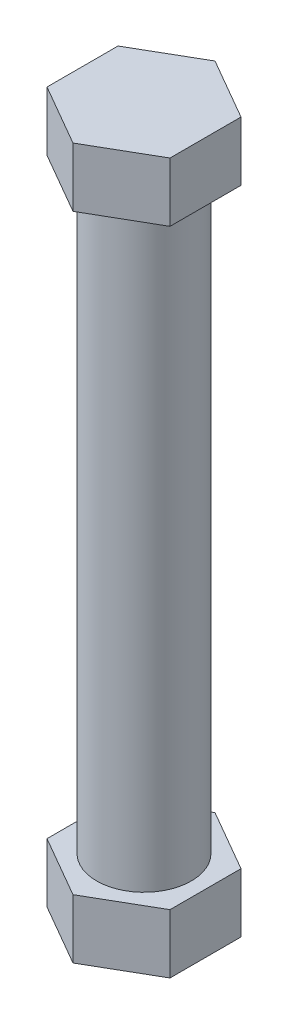
from build123d import *

# Parameters (mm, degrees)
SKETCH1_R           = 10.16
BOSS_EXTRUDE1_DEPTH = 127
BOSS_EXTRUDE2_DEPTH = 12.7
BOSS_EXTRUDE3_DEPTH = 12.7


with BuildPart() as part:
    # Sketch1 → Boss-Extrude1 (new body)
    with BuildSketch(Plane(origin=(0, 0, 0), x_dir=(1, 0, 0), z_dir=(0, 1, 0))):
        Circle(SKETCH1_R)
    extrude(amount=BOSS_EXTRUDE1_DEPTH)

    # Sketch2 → Boss-Extrude2 (add)
    with BuildSketch(Plane(origin=(0, 127, 0), x_dir=(1, 0, 0), z_dir=(0, 1, 0))):
        Polygon((0, 15.24), (-13.198227154, 7.62), (-13.198227154, -7.62), (0, -15.24), (13.198227154, -7.62), (13.198227154, 7.62), align=None)
    extrude(amount=BOSS_EXTRUDE2_DEPTH)

    # Sketch3 → Boss-Extrude3 (add)
    with BuildSketch(Plane.XZ):
        Polygon((-13.198227154, 7.62), (-13.198227154, -7.62), (0, -15.24), (13.198227154, -7.62), (13.198227154, 7.62), (0, 15.24), align=None)
    extrude(amount=BOSS_EXTRUDE3_DEPTH)


solid = part.part
